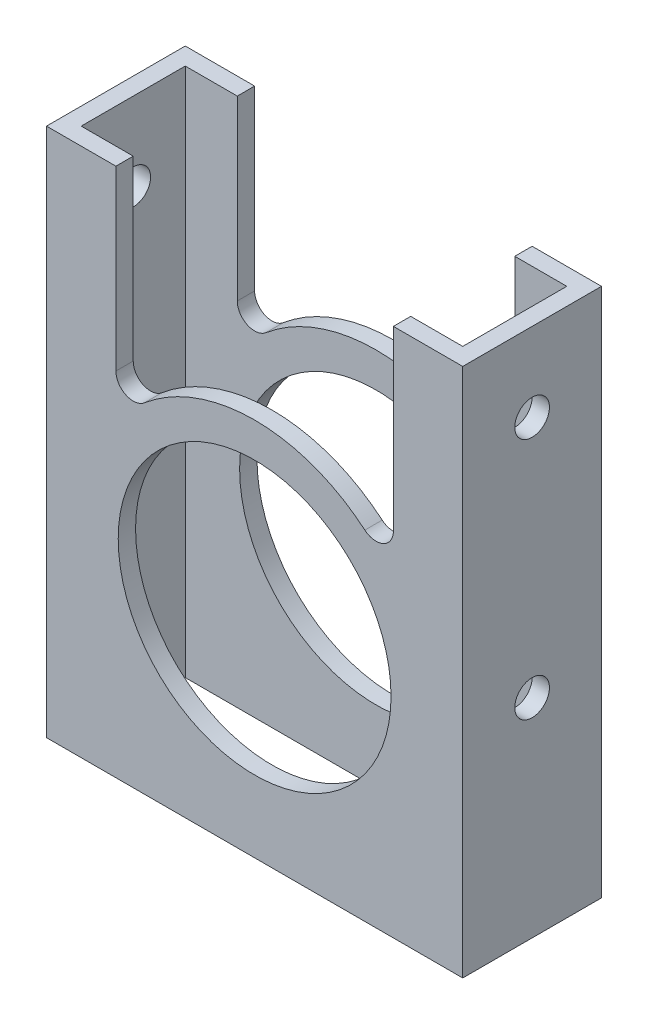
from build123d import *

# Parameters (mm, degrees)
SKETCH1_W           = 76.2
SKETCH1_H           = 25.4
SKETCH1_W_2         = 69.85
SKETCH1_H_2         = 19.05
EXTRUDE_THIN1_DEPTH = 50.8
SKETCH2_R           = 24.97201
CUT_EXTRUDE1_DEPTH  = 52.578
CUT_EXTRUDE2_DEPTH  = 26.4
SKETCH6_R           = 3.175
CUT_EXTRUDE3_DEPTH  = 77.2
SKETCH7_R           = 3.175
CUT_EXTRUDE4_DEPTH  = 77.2


with BuildPart() as part:
    # Sketch1 → Extrude-Thin1 (new body, symmetric)
    with BuildSketch(Plane(origin=(0, 0, 0), x_dir=(1, 0, 0), z_dir=(0, 1, 0))):
        with Locations((38.1, 12.7)):
            Rectangle(SKETCH1_W, SKETCH1_H)
        with Locations((38.1, 12.7)):
            Rectangle(SKETCH1_W_2, SKETCH1_H_2, mode=Mode.SUBTRACT)
    extrude(amount=EXTRUDE_THIN1_DEPTH, both=True)

    # Sketch2 → Cut-Extrude1 (cut)
    with BuildSketch(Plane(origin=(0, 0, -25.4), x_dir=(-1, 0, 0), z_dir=(0, 0, -1))):
        with Locations((-38.1, -12.7)):
            Circle(SKETCH2_R)
    extrude(amount=-CUT_EXTRUDE1_DEPTH, mode=Mode.SUBTRACT)

    # Sketch5 → Cut-Extrude2 (cut, through all)
    with BuildSketch(Plane(origin=(0, 0, -25.4), x_dir=(-1, 0, 0), z_dir=(0, 0, -1))):
        Polygon((0, 50.8), (-76.2, 50.8), (-76.2, 46.1645), (-63.5, 46.1645), (-12.7, 46.1645), (0, 46.1645), align=None)
        with BuildLine():
            Line((-12.7, 46.1645), (-63.5, 46.1645))
            Line((-63.5, 46.1645), (-63.5, 13.683575837))
            ThreePointArc((-63.5, 13.683575837), (-61.664047105, 10.804760481), (-58.279478519, 11.255311669))
            ThreePointArc((-58.279478519, 11.255311669), (-38.1, 18.62201), (-17.920521481, 11.255311669))
            ThreePointArc((-17.920521481, 11.255311669), (-14.535952895, 10.804760481), (-12.7, 13.683575837))
            Line((-12.7, 13.683575837), (-12.7, 46.1645))
        make_face()
    extrude(amount=-CUT_EXTRUDE2_DEPTH, mode=Mode.SUBTRACT)

    # Sketch6 → Cut-Extrude3 (cut, through all)
    with BuildSketch(Plane.ZY):
        with Locations((-12.7, 31.75)):
            Circle(SKETCH6_R)
    extrude(amount=-CUT_EXTRUDE3_DEPTH, mode=Mode.SUBTRACT)

    # Sketch7 → Cut-Extrude4 (cut, through all)
    with BuildSketch(Plane.ZY):
        with Locations((-12.7, -12.7)):
            Circle(SKETCH7_R)
    extrude(amount=-CUT_EXTRUDE4_DEPTH, mode=Mode.SUBTRACT)


solid = part.part
